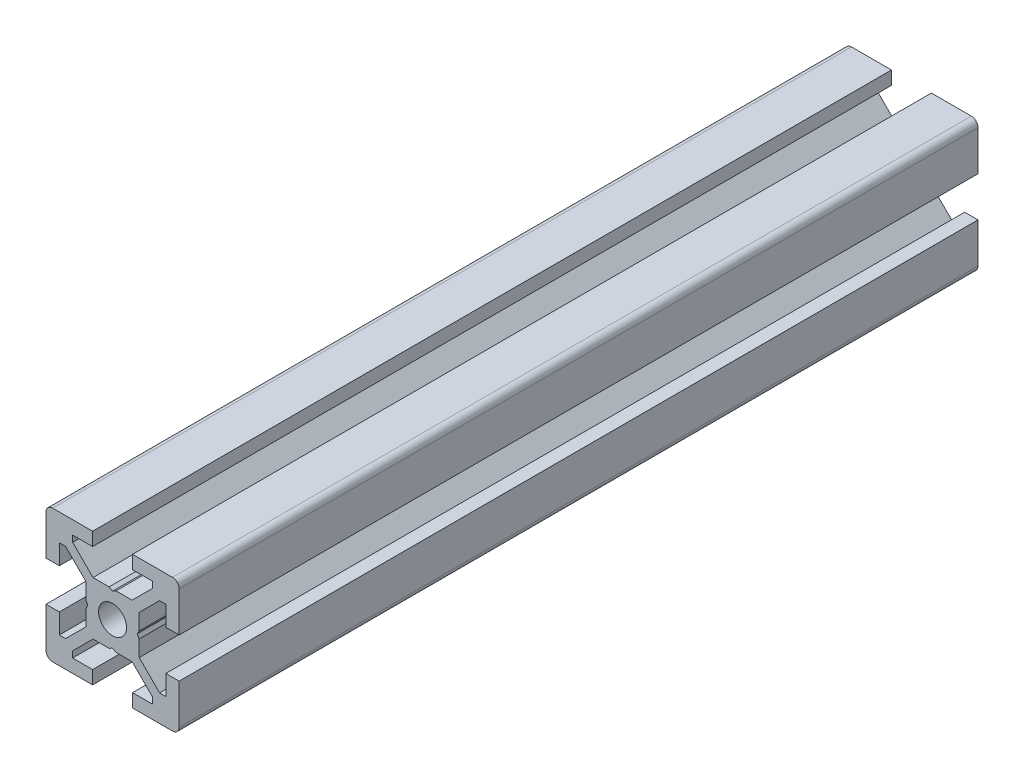
from build123d import *

# Parameters (mm, degrees)
EXTRUDE_1_DEPTH = 120
SKETCH_2_W      = 260
SKETCH_2_H      = 2.1


with BuildPart() as part:
    # ｽｹｯﾁ1 → ﾎﾞｽ - 押し出し1 (new body)
    with BuildSketch(Plane.XY):
        with BuildLine():
            Line((-10, -3), (-10, -9))
            ThreePointArc((-10, -9), (-9.707106781, -9.707106781), (-9, -10))
            Line((-9, -10), (-3, -10))
            Line((-3, -10), (-3, -8))
            Line((-3, -8), (-6, -8))
            Line((-6, -8), (-6, -7.060660172))
            Line((-6, -7.060660172), (-2.939339828, -4))
            Line((-2.939339828, -4), (-0.519615242, -4))
            Line((-0.519615242, -4), (0, -3.7))
            Line((0, -3.7), (0.519615242, -4))
            Line((0.519615242, -4), (2.939339828, -4))
            Line((2.939339828, -4), (6, -7.060660172))
            Line((6, -7.060660172), (6, -8))
            Line((6, -8), (3, -8))
            Line((3, -8), (3, -10))
            Line((3, -10), (9, -10))
            ThreePointArc((9, -10), (9.707106781, -9.707106781), (10, -9))
            Line((10, -9), (10, -3))
            Line((10, -3), (8, -3))
            Line((8, -3), (8, -6))
            Line((8, -6), (7.060660172, -6))
            Line((7.060660172, -6), (4, -2.939339828))
            Line((4, -2.939339828), (4, -0.519615242))
            Line((4, -0.519615242), (3.7, 0))
            Line((3.7, 0), (4, 0.519615242))
            Line((4, 0.519615242), (4, 2.939339828))
            Line((4, 2.939339828), (7.060660172, 6))
            Line((7.060660172, 6), (8, 6))
            Line((8, 6), (8, 3))
            Line((8, 3), (10, 3))
            Line((10, 3), (10, 9))
            ThreePointArc((10, 9), (9.707106781, 9.707106781), (9, 10))
            Line((9, 10), (3, 10))
            Line((3, 10), (3, 8))
            Line((3, 8), (6, 8))
            Line((6, 8), (6, 7.060660172))
            Line((6, 7.060660172), (2.939339828, 4))
            Line((2.939339828, 4), (0.519615242, 4))
            Line((0.519615242, 4), (0, 3.7))
            Line((0, 3.7), (-0.519615242, 4))
            Line((-0.519615242, 4), (-2.939339828, 4))
            Line((-2.939339828, 4), (-6, 7.060660172))
            Line((-6, 7.060660172), (-6, 8))
            Line((-6, 8), (-3, 8))
            Line((-3, 8), (-3, 10))
            Line((-3, 10), (-9, 10))
            ThreePointArc((-9, 10), (-9.707106781, 9.707106781), (-10, 9))
            Line((-10, 9), (-10, 3))
            Line((-10, 3), (-8, 3))
            Line((-8, 3), (-8, 6))
            Line((-8, 6), (-7.060660172, 6))
            Line((-7.060660172, 6), (-4, 2.939339828))
            Line((-4, 2.939339828), (-4, 0.519615242))
            Line((-4, 0.519615242), (-3.7, 0))
            Line((-3.7, 0), (-4, -0.519615242))
            Line((-4, -0.519615242), (-4, -2.939339828))
            Line((-4, -2.939339828), (-7.060660172, -6))
            Line((-7.060660172, -6), (-8, -6))
            Line((-8, -6), (-8, -3))
            Line((-8, -3), (-10, -3))
        make_face()
    extrude(amount=-EXTRUDE_1_DEPTH)

    # ｽｹｯﾁ2 → ｶｯﾄ - 回転1 (revolve, cut)
    with BuildSketch(Plane(origin=(0, 0, 0), x_dir=(0, 0, -1), z_dir=(1, 0, 0))):
        with Locations((130, 1.05)):
            Rectangle(SKETCH_2_W, SKETCH_2_H)
    revolve(axis=Axis((0, 0, -260), (0, 0, 1)), mode=Mode.SUBTRACT)


solid = part.part
